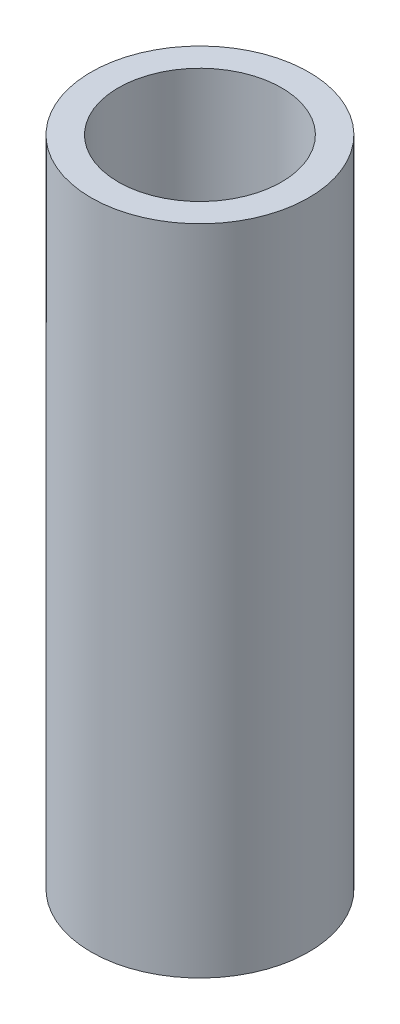
from build123d import *

# Parameters (mm, degrees)
SKETCH1_R           = 12.7
SKETCH1_R_2         = 9.525
BOSS_EXTRUDE2_DEPTH = 76.2


with BuildPart() as part:
    # Sketch1 → Boss-Extrude2 (new body)
    with BuildSketch(Plane(origin=(0, 0, 0), x_dir=(1, 0, 0), z_dir=(0, 1, 0))):
        Circle(SKETCH1_R)
        Circle(SKETCH1_R_2, mode=Mode.SUBTRACT)
    extrude(amount=BOSS_EXTRUDE2_DEPTH)


solid = part.part
